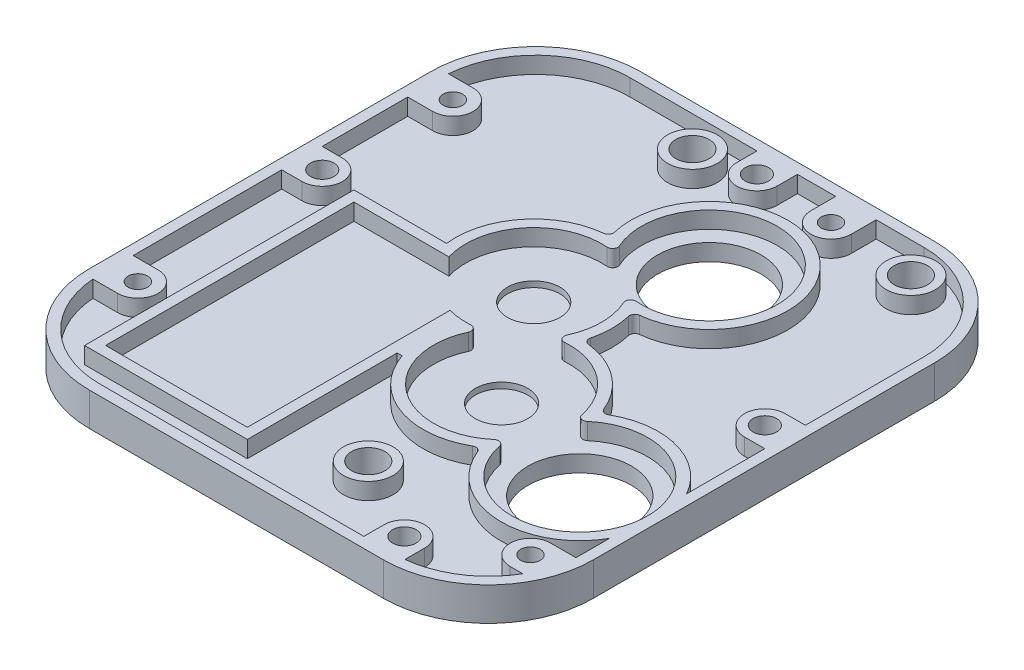
from build123d import *

# Parameters (mm, degrees)
W_TOP_DEPTH                                   = 3.175
SKETCH2_R                                     = 3.175
SKETCH2_R_2                                   = 9.855
HOLE_CLEARANCES_DEPTH                         = 3.175
SKETCH3_R                                     = 5
GEAR_PLACEMENT_CLEARANCES_DEPTH               = 1.12
SKETCH4_R                                     = 4.725
SKETCH4_R_2                                   = 3.175
TUBE_SHELL_DEPTH                              = 3.18
SKETCH5_R                                     = 4.725
SKETCH5_R_2                                   = 3.175
GEAR_SHELL_DEPTH                              = 3.18
SLIDER_GROOVE_DEPTH                           = 2.5
BLOCK_GROOVE_DEPTH                            = 0.5
CSK_FOR_8_FLAT_HEAD_SOCKET_CAP_SCREW1_A_COUNT = 2
CSK_FOR_8_FLAT_HEAD_SOCKET_CAP_SCREW1_A_PITCH = 86.221580796
CSK_FOR_8_FLAT_HEAD_SOCKET_CAP_SCRE_2_COUNT   = 2
CSK_FOR_8_FLAT_HEAD_SOCKET_CAP_SCRE_2_PITCH   = 96.878101329
CSK_FOR_8_FLAT_HEAD_SOCKET_CAP_SCRE_3_COUNT   = 2
CSK_FOR_8_FLAT_HEAD_SOCKET_CAP_SCRE_3_PITCH   = 55.021989197
SKETCH14_R                                    = 1.85
INSERTS_DEPTH                                 = 3.5
SKETCH15_R                                    = 2.233957976
SKETCH15_R_2                                  = 1.85
HOLE_DEPTH_TOLERANCE_DEPTH                    = 3.18


with BuildPart() as part:
    # Sketch1 → w_top (new body)
    with BuildSketch(Plane(origin=(0, 0, 0), x_dir=(1, 0, 0), z_dir=(0, 1, 0))):
        with BuildLine():
            Line((-48, -35), (-48, 30))
            ThreePointArc((-48, 30), (-42.142135624, 44.142135624), (-28, 50))
            Line((-28, 50), (28, 50))
            ThreePointArc((28, 50), (42.142135624, 44.142135624), (48, 30))
            Line((48, 30), (48, -35))
            ThreePointArc((48, -35), (42.142135624, -49.142135624), (28, -55))
            Line((28, -55), (-28, -55))
            ThreePointArc((-28, -55), (-42.142135624, -49.142135624), (-48, -35))
        make_face()
    extrude(amount=W_TOP_DEPTH)

    # Sketch2 → hole_clearances (cut)
    with BuildSketch(Plane.XZ):
        with Locations((10.3, 40.17)):
            Circle(SKETCH2_R)
        with Locations((31.3, -42.17)):
            Circle(SKETCH2_R)
        with Locations((-10.3, -42.17)):
            Circle(SKETCH2_R)
        with Locations((10.5, -24.585522991)):
            Circle(SKETCH2_R_2)
        with Locations((32.995036048, 22.59)):
            Circle(SKETCH2_R_2)
    extrude(amount=-HOLE_CLEARANCES_DEPTH, mode=Mode.SUBTRACT)

    # Sketch3 → gear placement clearances (cut)
    with BuildSketch(Plane(origin=(0, 3.175, 0), x_dir=(1, 0, 0), z_dir=(0, 1, 0))):
        with Locations((-3.329437252, 4.970562748)):
            Circle(SKETCH3_R)
        with Locations((10.3, -14.783890932)):
            Circle(SKETCH3_R)
    extrude(amount=-GEAR_PLACEMENT_CLEARANCES_DEPTH, mode=Mode.SUBTRACT)

    # Sketch4 → tube shell (add)
    with BuildSketch(Plane(origin=(0, 3.175, 0), x_dir=(1, 0, 0), z_dir=(0, 1, 0))):
        with Locations((-10.3, 42.17)):
            Circle(SKETCH4_R)
        with Locations((-10.3, 42.17)):
            Circle(SKETCH4_R_2, mode=Mode.SUBTRACT)
        with Locations((31.3, 42.17)):
            Circle(SKETCH4_R)
        with Locations((31.3, 42.17)):
            Circle(SKETCH4_R_2, mode=Mode.SUBTRACT)
        with Locations((10.3, -40.17)):
            Circle(SKETCH4_R)
        with Locations((10.3, -40.17)):
            Circle(SKETCH4_R_2, mode=Mode.SUBTRACT)
    extrude(amount=TUBE_SHELL_DEPTH)

    # Sketch5 → gear shell (add)
    with BuildSketch(Plane(origin=(0, 3.175, 0), x_dir=(1, 0, 0), z_dir=(0, 1, 0))):
        with Locations((-10.3, 42.17)):
            Circle(SKETCH5_R)
        with Locations((-10.3, 42.17)):
            Circle(SKETCH5_R_2, mode=Mode.SUBTRACT)
        with Locations((31.3, 42.17)):
            Circle(SKETCH5_R)
        with Locations((31.3, 42.17)):
            Circle(SKETCH5_R_2, mode=Mode.SUBTRACT)
        with Locations((10.3, -40.17)):
            Circle(SKETCH5_R)
        with Locations((10.3, -40.17)):
            Circle(SKETCH5_R_2, mode=Mode.SUBTRACT)
        with BuildLine():
            Line((-48, -35), (-48, 30))
            ThreePointArc((-48, 30), (-42.142135624, 44.142135624), (-28, 50))
            Line((-28, 50), (28, 50))
            ThreePointArc((28, 50), (42.142135624, 44.142135624), (48, 30))
            Line((48, 30), (48, -35))
            ThreePointArc((48, -35), (42.142135624, -49.142135624), (28, -55))
            Line((28, -55), (-28, -55))
            ThreePointArc((-28, -55), (-42.142135624, -49.142135624), (-48, -35))
        make_face()
        with BuildLine():
            Line((-17.78571907, 1.2), (-15.707821703, 1.2))
            ThreePointArc((-15.707821703, 1.2), (-13.410110046, 13.083612797), (-2.292509265, 17.868869824))
            ThreePointArc((-2.292509265, 17.868869824), (-1.395085224, 18.28942737), (-1.300434944, 19.275976852))
            ThreePointArc((-1.300434944, 19.275976852), (17.956325831, 35.161190827), (9.463072013, 11.687215915))
            ThreePointArc((9.463072013, 11.687215915), (8.565647973, 11.266658369), (8.470997693, 10.280108887))
            ThreePointArc((8.470997693, 10.280108887), (9.610316377, 4.90482769), (8.416444127, -0.458600697))
            ThreePointArc((8.416444127, -0.458600697), (8.501066268, -1.446060899), (9.394171163, -1.875714485))
            ThreePointArc((9.394171163, -1.875714485), (18.121445414, -4.47532475), (22.97524859, -12.180120925))
            ThreePointArc((22.97524859, -12.180120925), (23.629540133, -12.92452749), (24.60330923, -12.740103245))
            ThreePointArc((24.60330923, -12.740103245), (45.231367899, -26.79876798), (20.319787458, -25.193770006))
            ThreePointArc((20.319787458, -25.193770006), (19.665495915, -24.449363441), (18.691726818, -24.633787687))
            ThreePointArc((18.691726818, -24.633787687), (2.478554586, -25.092457113), (-1.445881378, -9.354727487))
            ThreePointArc((-1.445881378, -9.354727487), (-1.53050352, -8.367267285), (-2.423608415, -7.937613699))
            ThreePointArc((-2.423608415, -7.937613699), (-4.630738211, -7.903759016), (-6.8, -7.4952601))
            Line((-6.8, -7.4952601), (-6.8, -9.560659556))
            Line((-6.8, -9.560659556), (-6.8, -46.1))
            Line((-6.8, -46.1), (-33.8, -46.1))
            Line((-33.8, -46.1), (-33.8, 1.2))
            Line((-33.8, 1.2), (-17.78571907, 1.2))
        make_face(mode=Mode.SUBTRACT)
        with BuildLine():
            Line((-4.8, -48.1), (-35.8, -48.1))
            Line((-35.8, -48.1), (-35.8, 3.2))
            Line((-35.8, 3.2), (-18.16407021, 3.2))
            ThreePointArc((-18.16407021, 3.2), (-15.004056795, 14.292820306), (-4.885529953, 19.829223622))
            ThreePointArc((-4.885529953, 19.829223622), (-4.172396635, 20.24755797), (-4.017932328, 21.059779328))
            ThreePointArc((-4.017932328, 21.059779328), (19.108778935, 36.795770847), (12.056092702, 9.726862117))
            ThreePointArc((12.056092702, 9.726862117), (11.342959383, 9.308527769), (11.188495077, 8.496306411))
            ThreePointArc((11.188495077, 8.496306411), (11.610290571, 4.89466765), (11.151924524, 1.297500184))
            ThreePointArc((11.151924524, 1.297500184), (11.298128762, 0.483751404), (12.006975035, 0.058193278))
            ThreePointArc((12.006975035, 0.058193278), (19.330331566, -2.882028083), (24.134091671, -9.143045684))
            ThreePointArc((24.134091671, -9.143045684), (24.734818732, -9.711103563), (25.557877687, -9.632766384))
            ThreePointArc((25.557877687, -9.632766384), (36.944835985, -8.181658391), (46, -15.2366239))
            Line((46, -15.2366239), (46, 30))
            ThreePointArc((46, 30), (40.727922061, 42.727922061), (28, 48))
            Line((28, 48), (-28, 48))
            ThreePointArc((-28, 48), (-40.727922061, 42.727922061), (-46, 30))
            Line((-46, 30), (-46, -35))
            ThreePointArc((-46, -35), (-40.727922061, -47.727922061), (-28, -53))
            Line((-28, -53), (28, -53))
            ThreePointArc((28, -53), (40.727922061, -47.727922061), (46, -35))
            Line((46, -35), (46, -29.9433761))
            ThreePointArc((46, -29.9433761), (32.043692959, -37.499600055), (19.160944377, -28.230845247))
            ThreePointArc((19.160944377, -28.230845247), (18.560217315, -27.662787368), (17.737158361, -27.741124548))
            ThreePointArc((17.737158361, -27.741124548), (5.010925396, -28.756253556), (-3.853084155, -19.568390526))
            Line((-3.853084155, -19.568390526), (-4.8, -19.568390526))
            Line((-4.8, -19.568390526), (-4.8, -48.1))
        make_face(mode=Mode.SUBTRACT)
    extrude(amount=GEAR_SHELL_DEPTH)

    # Sketch6 → slider groove (cut)
    with BuildSketch(Plane.XZ):
        Polygon((22.3, 33.395), (22.3, 27.395), (-1.7, 27.395), (-1.7, 33.395), (-1.7, 35.8), (22.3, 35.8), align=None)
        Polygon((-22.3, -29.390522991), (1.7, -29.390522991), (1.7, -35.390522991), (1.7, -37.8), (-22.3, -37.8), (-22.3, -35.390522991), align=None)
        Polygon((43.3, -35.390522991), (43.3, -29.390522991), (19.3, -29.390522991), (19.3, -35.390522991), (19.3, -37.8), (43.3, -37.8), align=None)
    extrude(amount=-SLIDER_GROOVE_DEPTH, mode=Mode.SUBTRACT)

    # Sketch7 → block groove (cut)
    with BuildSketch(Plane.XZ):
        Polygon((-20.3, 11.59), (0, 11.59), (0, -13.585522991), (0, -28.390522991), (-20.3, -28.390522991), align=None)
        Polygon((21, -13.585522991), (21, -28.390522991), (41.3, -28.390522991), (41.3, 11.59), (21, 11.59), align=None)
        Polygon((20.3, -13.585522991), (0.3, -13.585522991), (0.3, 11.59), (0.3, 26.395), (20.3, 26.395), (20.3, 11.59), align=None)
    extrude(amount=-BLOCK_GROOVE_DEPTH, mode=Mode.SUBTRACT)

    # Sketch11 → CSK for #8 Flat Head Socket Cap Screw1 (revolve, cut)
    with BuildSketch(Plane(origin=(26.142135624, 0, 49.142135624), x_dir=(0, 0, -1), z_dir=(1, 0, 0))):
        Polygon((0, 0), (0, 7.647442612), (2.15265, 6.354), (2.15265, 3.268534127), (4.5593, 0.5), (4.5593, 0), align=None)
    csk_for_8_flat_head_socket_cap_screw1 = revolve(axis=Axis((26.142135624, -6.35, 49.142135624), (0, 1, 0)), mode=Mode.SUBTRACT)

    # CSK for #8 Flat Head Socket Cap Screw1 a: CSK for #8 Flat Head Socket Cap Screw1 ×2
    with Locations(*[Vector(-0.791962646, 0, -0.610569544) * (i * CSK_FOR_8_FLAT_HEAD_SOCKET_CAP_SCREW1_A_PITCH) for i in range(1, CSK_FOR_8_FLAT_HEAD_SOCKET_CAP_SCREW1_A_COUNT)]):
        add(csk_for_8_flat_head_socket_cap_screw1, mode=Mode.SUBTRACT)

    # CSK for _8 Flat Head Socket Cap Scre 2: CSK for #8 Flat Head Socket Cap Screw1 ×2
    with Locations(*[Vector(-0.269845664, 0, -0.962903587) * (i * CSK_FOR_8_FLAT_HEAD_SOCKET_CAP_SCRE_2_PITCH) for i in range(1, CSK_FOR_8_FLAT_HEAD_SOCKET_CAP_SCRE_2_COUNT)]):
        add(csk_for_8_flat_head_socket_cap_screw1, mode=Mode.SUBTRACT)

    # CSK for _8 Flat Head Socket Cap Scre 3: CSK for #8 Flat Head Socket Cap Screw1 ×2
    with Locations(*[Vector(0.290792831, 0, -0.956786042) * (i * CSK_FOR_8_FLAT_HEAD_SOCKET_CAP_SCRE_3_PITCH) for i in range(1, CSK_FOR_8_FLAT_HEAD_SOCKET_CAP_SCRE_3_COUNT)]):
        add(csk_for_8_flat_head_socket_cap_screw1, mode=Mode.SUBTRACT)

    # Sketch14 → inserts (cut)
    with BuildSketch(Plane.XZ):
        with Locations((-41.25, 32.5)):
            Circle(SKETCH14_R)
        with Locations((-41.25, -27.5)):
            Circle(SKETCH14_R)
        with Locations((15, -43.25)):
            Circle(SKETCH14_R)
        with Locations((41.190590308, 40.17)):
            Circle(SKETCH14_R)
    extrude(amount=-INSERTS_DEPTH, mode=Mode.SUBTRACT)

    # Sketch15 → hole depth tolerance (add)
    with BuildSketch(Plane(origin=(0, 3.175, 0), x_dir=(1, 0, 0), z_dir=(0, 1, 0))):
        with BuildLine():
            Line((-42.142135624, 7.36), (-46, 7.36))
            Line((-46, 7.36), (-46, -0.355728753))
            Line((-46, -0.355728753), (-42.142135624, -0.355728753))
            ThreePointArc((-42.142135624, -0.355728753), (-38.284271247, 3.502135624), (-42.142135624, 7.36))
        make_face()
        with Locations((-42.142135624, 3.502135624)):
            Circle(SKETCH15_R, mode=Mode.SUBTRACT)
        with BuildLine():
            Line((3.857864376, 44.142135624), (3.857864376, 48))
            Line((3.857864376, 48), (-3.857864376, 48))
            Line((-3.857864376, 48), (-3.857864376, 44.142135624))
            ThreePointArc((-3.857864376, 44.142135624), (0, 40.284271247), (3.857864376, 44.142135624))
        make_face()
        with Locations((0, 44.142135624)):
            Circle(SKETCH15_R, mode=Mode.SUBTRACT)
        with BuildLine():
            Line((22.284271247, -49.142135624), (22.284271247, -53))
            Line((22.284271247, -53), (30, -53))
            Line((30, -53), (30, -49.142135624))
            ThreePointArc((30, -49.142135624), (26.142135624, -45.284271247), (22.284271247, -49.142135624))
        make_face()
        with Locations((26.142135624, -49.142135624)):
            Circle(SKETCH15_R, mode=Mode.SUBTRACT)
        with BuildLine():
            Line((42.142135624, 7.36), (46, 7.38168805))
            Line((46, 7.38168805), (46, -0.355728753))
            Line((46, -0.355728753), (42.142135624, -0.355728753))
            ThreePointArc((42.142135624, -0.355728753), (38.284271247, 3.502135624), (42.142135624, 7.36))
        make_face()
        with Locations((42.142135624, 3.502135624)):
            Circle(SKETCH15_R, mode=Mode.SUBTRACT)
        with BuildLine():
            Line((41.190590308, -36.312135624), (45.952111299, -36.312135624))
            ThreePointArc((45.952111299, -36.312135624), (45.34365383, -40.349331376), (43.572336524, -44.027864376))
            Line((43.572336524, -44.027864376), (41.190590308, -44.027864376))
            ThreePointArc((41.190590308, -44.027864376), (37.332725932, -40.17), (41.190590308, -36.312135624))
        make_face()
        with Locations((41.190590308, -40.17)):
            Circle(SKETCH15_R_2, mode=Mode.SUBTRACT)
        with BuildLine():
            Line((-41.25, -28.642135624), (-46, -28.642135624))
            Line((-46, -28.642135624), (-46, -35))
            ThreePointArc((-46, -35), (-45.987173025, -35.679416347), (-45.948710381, -36.357864376))
            Line((-45.948710381, -36.357864376), (-41.25, -36.357864376))
            ThreePointArc((-41.25, -36.357864376), (-37.392135624, -32.5), (-41.25, -28.642135624))
        make_face()
        with Locations((-41.25, -32.5)):
            Circle(SKETCH15_R_2, mode=Mode.SUBTRACT)
        with BuildLine():
            Line((18.857864376, 43.25), (18.857864376, 48))
            Line((18.857864376, 48), (11.142135624, 48))
            Line((11.142135624, 48), (11.142135624, 43.25))
            ThreePointArc((11.142135624, 43.25), (15, 39.392135624), (18.857864376, 43.25))
        make_face()
        with Locations((15, 43.25)):
            Circle(SKETCH15_R_2, mode=Mode.SUBTRACT)
        with BuildLine():
            Line((-41.25, 31.357864376), (-45.948710381, 31.357864376))
            ThreePointArc((-45.948710381, 31.357864376), (-45.987173025, 30.679416347), (-46, 30))
            Line((-46, 30), (-46, 23.642135624))
            Line((-46, 23.642135624), (-41.25, 23.642135624))
            ThreePointArc((-41.25, 23.642135624), (-37.392135624, 27.5), (-41.25, 31.357864376))
        make_face()
        with Locations((-41.25, 27.5)):
            Circle(SKETCH15_R_2, mode=Mode.SUBTRACT)
    extrude(amount=HOLE_DEPTH_TOLERANCE_DEPTH)


solid = part.part
